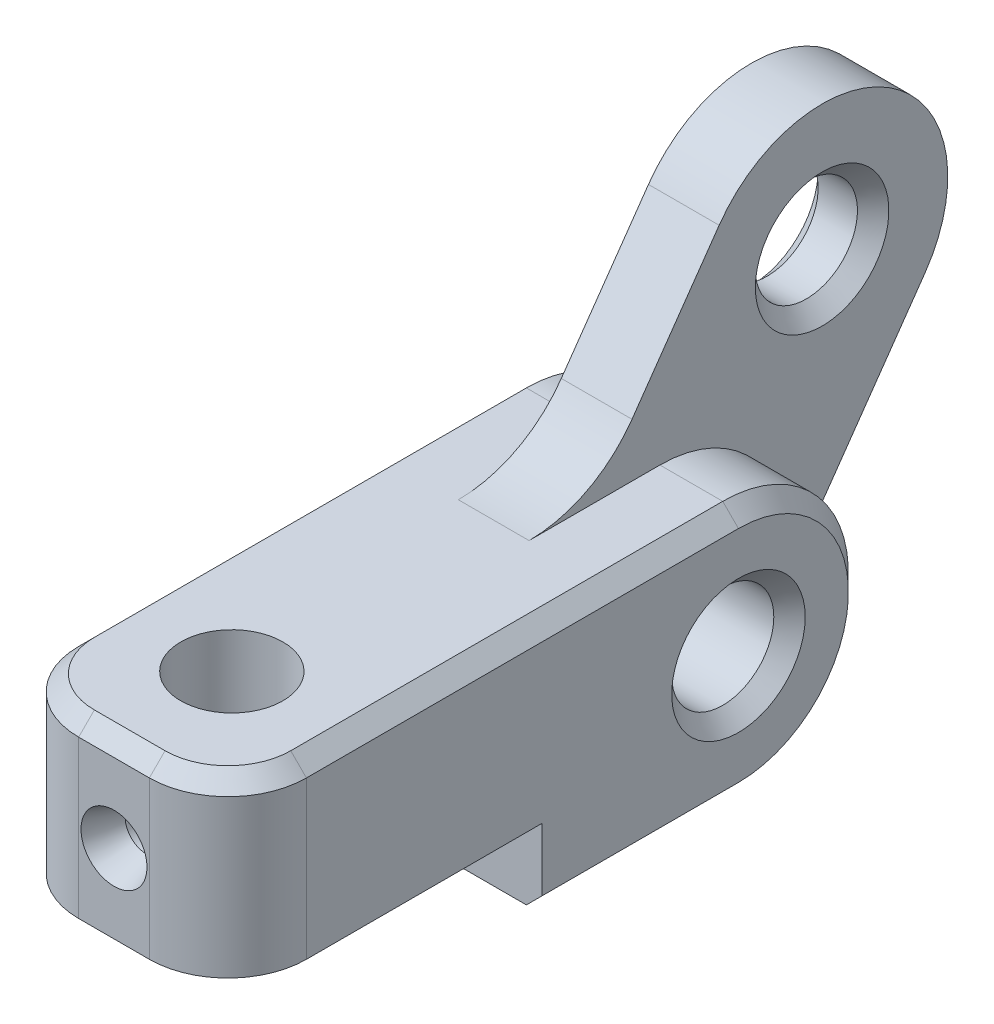
from build123d import *

# Parameters (mm, degrees)
SKETCH1_R           = 3.25
BOSS_EXTRUDE1_DEPTH = 2.25
SKETCH2_R           = 3.25
BOSS_EXTRUDE2_DEPTH = 5
SKETCH3_R           = 3.25
CUT_EXTRUDE1_DEPTH  = 26.744736797
FILLET1_R           = 5
CHAMFER1_SIZE       = 1
CUT_EXTRUDE2_REACH  = 52.824
SKETCH4_R           = 1.35
CHAMFER2_SIZE       = 0.75
CHAMFER2_SIZE2      = 2.060608065
CHAMFER3_SIZE       = 1


with BuildPart() as part:
    # Sketch1 → Boss-Extrude1 (new body, symmetric)
    with BuildSketch(Plane(origin=(0, 0, 0), x_dir=(0, 0, -1), z_dir=(1, 0, 0))):
        with BuildLine():
            Line((-1.775856455, 11.411388509), (3.7711595, 19.333348288))
            ThreePointArc((3.7711595, 19.333348288), (14.912987345, 21.297953152), (16.877592209, 10.156125306))
            Line((16.877592209, 10.156125306), (6.553216354, -4.588611491))
            ThreePointArc((6.553216354, -4.588611491), (3.693988906, -7.096086665), (0, -8))
            Line((0, -8), (-12.5, -8))
            Line((-12.5, -8), (-12.5, -3))
            Line((-12.5, -3), (-32.5, -3))
            Line((-32.5, -3), (-32.5, 8))
            Line((-32.5, 8), (-25, 8))
            Line((-25, 8), (-8.329072809, 8))
            ThreePointArc((-8.329072809, 8), (-4.635083903, 8.903913335), (-1.775856455, 11.411388509))
        make_face()
        Circle(SKETCH1_R, mode=Mode.SUBTRACT)
        with Locations((10.324375854, 14.744736797)):
            Circle(SKETCH1_R, mode=Mode.SUBTRACT)
    extrude(amount=BOSS_EXTRUDE1_DEPTH, both=True)

    # Sketch2 → Boss-Extrude2 (add)
    with BuildSketch(Plane(origin=(2.25, 0, 0), x_dir=(0, 0, -1), z_dir=(1, 0, 0))):
        with BuildLine():
            Line((-32.5, 8), (0, 8))
            ThreePointArc((0, 8), (8, 0), (0, -8))
            Line((0, -8), (-12.5, -8))
            Line((-12.5, -8), (-12.5, -3))
            Line((-12.5, -3), (-32.5, -3))
            Line((-32.5, -3), (-32.5, 8))
        make_face()
        Circle(SKETCH2_R, mode=Mode.SUBTRACT)
    boss_extrude2 = extrude(amount=BOSS_EXTRUDE2_DEPTH)

    # Mirror1: Boss-Extrude2 across plane
    add(boss_extrude2.mirror(Plane(origin=(0, 0, 0), x_dir=(0, 0, 1), z_dir=(1, 0, 0))))

    # Sketch3 → Cut-Extrude1 (cut, through all)
    with BuildSketch(Plane.XZ.offset(3)):
        with Locations((0, 25)):
            Circle(SKETCH3_R)
    extrude(amount=-CUT_EXTRUDE1_DEPTH, mode=Mode.SUBTRACT)

    # Fillet1
    fillet1_edges = [part.edges().sort_by_distance(p)[0] for p in [
        (7.25, 2.5, 32.5),
        (-7.25, 2.5, 32.5),
    ]]
    fillet(fillet1_edges, radius=FILLET1_R)

    # Chamfer1
    chamfer1_edges = [part.edges().sort_by_distance(p)[0] for p in [
        (0, 8, 32.5),
        (5.785533906, 8, 31.035533906),
        (-5.785533906, 8, 31.035533906),
        (-2.25, 14.744736797, -7.074375854),
        (2.25, 14.744736797, -7.074375854),
        (7.25, -8, 6.25),
        (7.25, 0, -8),
        (7.25, 8, 13.75),
        (7.25, 0, 3.25),
        (-7.25, 8, 13.75),
        (-7.25, 0, -8),
        (-7.25, -8, 6.25),
        (-7.25, 0, 3.25),
    ]]
    chamfer(chamfer1_edges, length=CHAMFER1_SIZE)

    # Sketch4 → Cut-Extrude2 (cut, up to next)
    with BuildSketch(Plane.XY.offset(32.5), mode=Mode.PRIVATE) as cut_extrude2_sk1:
        with Locations((0, 2)):
            Circle(SKETCH4_R)
    cut_extrude2_tool1 = extrude(cut_extrude2_sk1.sketch, amount=-CUT_EXTRUDE2_REACH, mode=Mode.PRIVATE) & part.part
    add(cut_extrude2_tool1.solids().sort_by_distance((0, 2, 32.5))[0], mode=Mode.SUBTRACT)

    # Chamfer2
    chamfer2_edges = [part.edges().sort_by_distance(p)[0] for p in [
        (-1.35, 2, 32.5),
    ]]
    chamfer2_side = [part.faces().sort_by_distance(p)[0] for p in [
        (-2.140341439, 2, 32.5),
    ]]
    chamfer(chamfer2_edges, length=CHAMFER2_SIZE, length2=CHAMFER2_SIZE2, reference=chamfer2_side[0])

    # Chamfer3
    chamfer3_edges = [part.edges().sort_by_distance(p)[0] for p in [
        (-3.25, -3, 25),
    ]]
    chamfer(chamfer3_edges, length=CHAMFER3_SIZE)


solid = part.part
